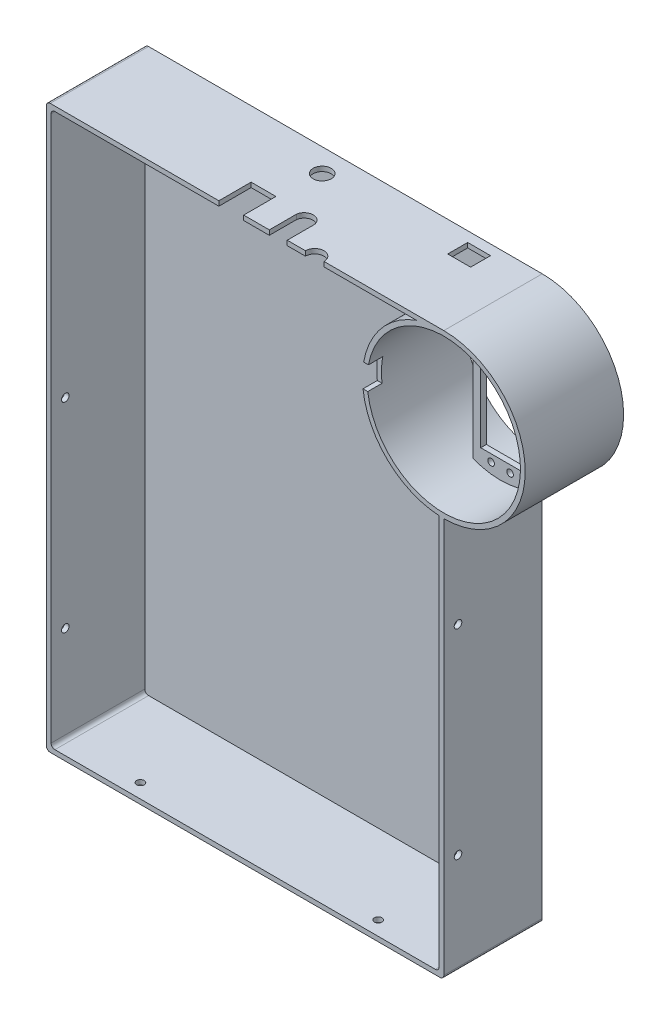
from build123d import *
from build123d.topology import SkipClean

# Parameters (mm, degrees)
SKETCH_1_R             = 43
SKETCH_1_R_2           = 1.75
EXTRUDE_1_DEPTH        = 3
EXTRUDE_1_2_DEPTH      = 19
EXTRUDE_1_2_DEPTH_BACK = 33
SKETCH_3_R             = 43
SKETCH_3_R_2           = 40.5
EXTRUDE_START          = -52
EXTRUDE_2_DEPTH        = 52
EXTRUDE_2_2_DEPTH      = 2.5
FILLET_1_R             = 2
SKETCH_6_W             = 12.068691
SKETCH_6_H             = 10.532676
CUT_EXTRUDE_1_DEPTH    = 3
SKETCH_7_R             = 2
CUT_EXTRUDE_2_DEPTH    = 283
SKETCH_8_R             = 2
CUT_EXTRUDE_3_DEPTH    = 10
SKETCH_9_W             = 13.11693
SKETCH_9_H             = 19.719399
CUT_EXTRUDE_4_DEPTH    = 10
SKETCH_10_W            = 7.55958
SKETCH_10_H            = 12.395118
CUT_EXTRUDE_5_DEPTH    = 61
SKETCH_11_W            = 11.880057
SKETCH_11_H            = 21.859304
CUT_EXTRUDE_6_DEPTH    = 61
SKETCH_12_R            = 4.8
CUT_EXTRUDE_7_DEPTH    = 10
SKETCH_13_R            = 4.906551
CUT_EXTRUDE_8_DEPTH    = 10


with BuildPart() as part:
    # Sketch 1 → Extrude 1 (new body)
    with BuildSketch(Plane.XY):
        with Locations((0, 10.35)):
            Circle(SKETCH_1_R)
        with Locations((-5, 24.315)):
            Circle(SKETCH_1_R_2, mode=Mode.SUBTRACT)
        with Locations((5, 24.315)):
            Circle(SKETCH_1_R_2, mode=Mode.SUBTRACT)
        with Locations((-5, -24.315)):
            Circle(SKETCH_1_R_2, mode=Mode.SUBTRACT)
        with Locations((5, -24.315)):
            Circle(SKETCH_1_R_2, mode=Mode.SUBTRACT)
        with BuildLine():
            Line((3.395324, 20.5), (10.5, 20.5))
            Line((10.5, 20.5), (10.5, -20.5))
            Line((10.5, -20.5), (-10.5, -20.5))
            Line((-10.5, -20.5), (-10.5, 20.5))
            Line((-10.5, 20.5), (-3.395324, 20.5))
            ThreePointArc((-3.395324, 20.5), (0, 23.895324), (3.395324, 20.5))
        make_face(mode=Mode.SUBTRACT)
        with BuildLine():
            Line((-14.5, 48.165341), (-14.5, -27.465341))
            ThreePointArc((-14.5, -27.465341), (-40.5, 10.35), (-14.5, 48.165341))
        make_face(mode=Mode.SUBTRACT)
        with BuildLine():
            Line((14.5, 48.165341), (14.5, -27.465341))
            ThreePointArc((14.5, -27.465341), (40.5, 10.35), (14.5, 48.165341))
        make_face(mode=Mode.SUBTRACT)
    extrude(amount=EXTRUDE_1_DEPTH)

    # Sketch 3 → Extrude 1 2 (add, two sides: drawn at the far end of the back side and taken through both)
    with SkipClean():  # the faces are left unmerged after this step: merging them gives an invalid solid
        with BuildSketch(Plane(origin=(0, 0, 0), x_dir=(-1, 0, 0), z_dir=(0, 0, -1)).offset(-EXTRUDE_1_2_DEPTH_BACK)):
            with Locations((0, 10.35)):
                Circle(SKETCH_3_R)
            with Locations((0, 10.35)):
                Circle(SKETCH_3_R_2, mode=Mode.SUBTRACT)
        extrude(amount=EXTRUDE_1_2_DEPTH + EXTRUDE_1_2_DEPTH_BACK)

    # Sketch 4 → Extrude 2 (add)
    with SkipClean():  # the faces are left unmerged after this step: merging them gives an invalid solid
        with BuildSketch(Plane(origin=(0, 0, -19), x_dir=(-1, 0, 0), z_dir=(0, 0, -1)).offset(EXTRUDE_START)):
            Polygon((0, 53.35), (210, 53.35), (210, -243.65), (0, -243.65), (0, -30.15), (2.5, -30.15), (2.5, -241.15), (207.5, -241.15), (207.5, 50.85), (0, 50.85), align=None)
        extrude(amount=EXTRUDE_2_DEPTH)

    # Sketch 5 → Extrude 2 2 (add)
    with SkipClean():  # the faces are left unmerged after this step: merging them gives an invalid solid
        with BuildSketch(Plane(origin=(0, 0, -19), x_dir=(-1, 0, 0), z_dir=(0, 0, -1))):
            with BuildLine():
                Line((2.5, -241.15), (2.5, -32.577264))
                ThreePointArc((2.5, -32.577264), (42.565682, 4.25388), (14.448183, 50.85))
                Line((14.448183, 50.85), (207.5, 50.85))
                Line((207.5, 50.85), (207.5, -241.15))
                Line((207.5, -241.15), (2.5, -241.15))
            make_face()
        extrude(amount=-EXTRUDE_2_2_DEPTH)

    # Fillet 1
    fillet_1_edges = [part.edges().sort_by_distance(p)[0] for p in [
        (-207.5, 50.85, 8.25),
        (0, -243.65, 7),
        (-207.5, -241.15, 8.25),
        (-2.5, -241.15, 8.25),
        (-210, -243.65, 7),
        (-210, 53.35, 7),
    ]]
    fillet(fillet_1_edges, radius=FILLET_1_R)

    # Sketch 6 → Cut-Extrude 1 (cut)
    with BuildSketch(Plane(origin=(0, 53.35, 0), x_dir=(1, 0, 0), z_dir=(0, 1, 0))):
        with Locations((-27.994546, 8.375655)):
            Rectangle(SKETCH_6_W, SKETCH_6_H)
    extrude(amount=-CUT_EXTRUDE_1_DEPTH, mode=Mode.SUBTRACT)

    # Sketch 7 → Cut-Extrude 2 (cut)
    with BuildSketch(Plane(origin=(0, 0, 0), x_dir=(0, 0, -1), z_dir=(1, 0, 0))):
        with Locations(Location((-25.5, -84.801057, 0), (0, 0, 270))):
            Circle(SKETCH_7_R)
        with Locations(Location((-25.5, -190.350496, 0), (0, 0, 270))):
            Circle(SKETCH_7_R)
    extrude(amount=-CUT_EXTRUDE_2_DEPTH, mode=Mode.SUBTRACT)

    # Sketch 8 → Cut-Extrude 3 (cut)
    with BuildSketch(Plane.XZ.offset(243.65)):
        with Locations(Location((-167.807889, 25.5, 0), (0, 0, 270))):
            Circle(SKETCH_8_R)
        with Locations(Location((-42.192111, 25.5, 0), (0, 0, 270))):
            Circle(SKETCH_8_R)
    extrude(amount=-CUT_EXTRUDE_3_DEPTH, mode=Mode.SUBTRACT)

    # Sketch 9 → Cut-Extrude 4 (cut)
    with BuildSketch(Plane(origin=(0, 53.35, 0), x_dir=(1, 0, 0), z_dir=(0, 1, 0))):
        with Locations((-112.297275, -25.832317)):
            Rectangle(SKETCH_9_W, SKETCH_9_H)
        with BuildLine():
            Line((-92.210137, -34.22374), (-82.740067, -34.22374))
            Line((-82.740067, -34.22374), (-82.740067, -18.619532))
            ThreePointArc((-82.740067, -18.619532), (-87.475102, -14.502019), (-92.210137, -18.619532))
            Line((-92.210137, -18.619532), (-92.210137, -34.22374))
        make_face()
    extrude(amount=-CUT_EXTRUDE_4_DEPTH, mode=Mode.SUBTRACT)

    # Sketch 10 → Cut-Extrude 5 (cut)
    with BuildSketch(Plane.ZY.offset(2.5)):
        with Locations((29.22021, 11.568763)):
            Rectangle(SKETCH_10_W, SKETCH_10_H)
    extrude(amount=CUT_EXTRUDE_5_DEPTH, mode=Mode.SUBTRACT)

    # Sketch 11 → Cut-Extrude 6 (cut)
    with BuildSketch(Plane(origin=(0, 0, -19), x_dir=(-1, 0, 0), z_dir=(0, 0, -1))):
        with Locations((93.214773, 23.896012)):
            Rectangle(SKETCH_11_W, SKETCH_11_H)
    extrude(amount=-CUT_EXTRUDE_6_DEPTH, mode=Mode.SUBTRACT)

    # Sketch 12 → Cut-Extrude 7 (cut)
    with BuildSketch(Plane(origin=(0, 53.35, 0), x_dir=(1, 0, 0), z_dir=(0, 1, 0))):
        with Locations(Location((-104, 6.738484, 0), (0, 0, 270))):
            Circle(SKETCH_12_R)
    extrude(amount=-CUT_EXTRUDE_7_DEPTH, mode=Mode.SUBTRACT)

    # Sketch 13 → Cut-Extrude 8 (cut)
    with BuildSketch(Plane(origin=(0, 53.35, 0), x_dir=(1, 0, 0), z_dir=(0, 1, 0))):
        with Locations((-68.22173, -33)):
            Circle(SKETCH_13_R)
    extrude(amount=-CUT_EXTRUDE_8_DEPTH, mode=Mode.SUBTRACT)


solid = part.part
